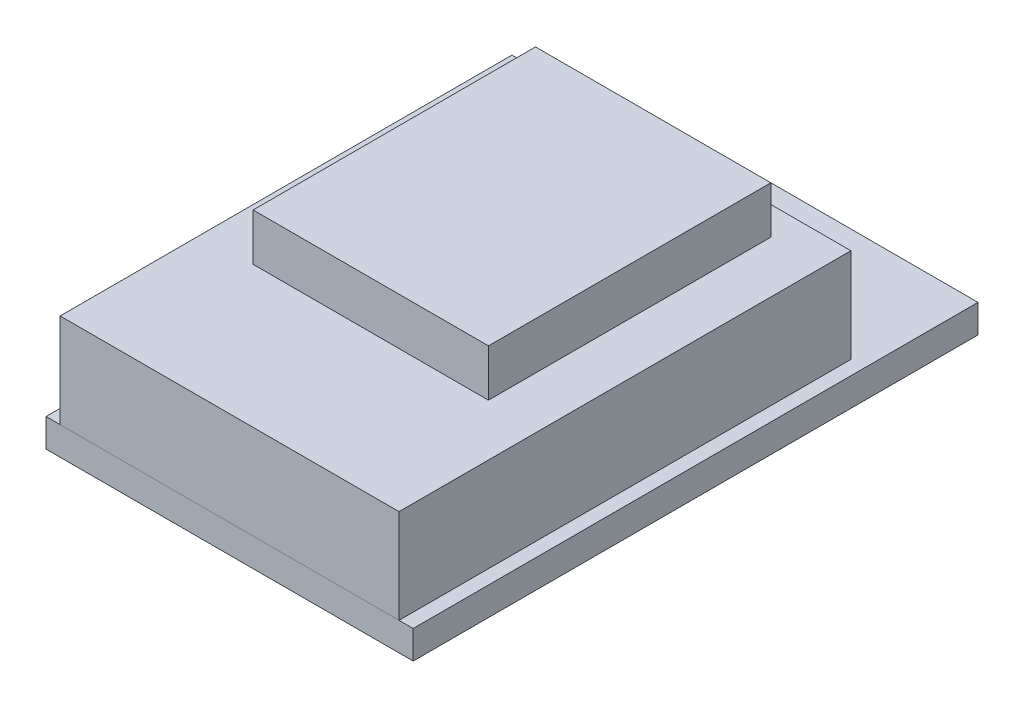
from build123d import *

# Parameters (mm, degrees)
SKETCH_1_W        = 19.5
SKETCH_1_H        = 30
EXTRUDE_1_DEPTH   = 1.5
SKETCH_2_W        = 2.54
SKETCH_2_H        = 20.32
EXTRUDE_2_DEPTH   = 2.54
EXTRUDE_2_2_DEPTH = 2.54
SKETCH_3_W        = 18
SKETCH_3_H        = 24
EXTRUDE_3_DEPTH   = 5
SKETCH_4_W        = 12.5
SKETCH_4_H        = 15
EXTRUDE_4_DEPTH   = 2.5


with BuildPart() as part:
    # Эскиз1 → Бобышка-Вытянуть1 (new body)
    with BuildSketch(Plane(origin=(0, 0, 0), x_dir=(1, 0, 0), z_dir=(0, 1, 0))):
        Rectangle(SKETCH_1_W, SKETCH_1_H)
    extrude(amount=EXTRUDE_1_DEPTH)


with BuildPart() as body_2:
    # Эскиз2 → Бобышка-Вытянуть2 (new body)
    with BuildSketch(Plane.XZ):
        with Locations((-3.81, 1.03)):
            Rectangle(SKETCH_2_W, SKETCH_2_H)
    extrude(amount=EXTRUDE_2_DEPTH)


with BuildPart() as body_3:
    # Эскиз2 → Extrude 2 2 (new body)
    with BuildSketch(Plane.XZ):
        with Locations((3.81, 1.03)):
            Rectangle(SKETCH_2_W, SKETCH_2_H)
    extrude(amount=EXTRUDE_2_2_DEPTH)


with BuildPart() as body_4:
    # Эскиз3 → Бобышка-Вытянуть3 (new body)
    with BuildSketch(Plane(origin=(0, 1.5, 0), x_dir=(1, 0, 0), z_dir=(0, 1, 0))):
        with Locations((0, -3)):
            Rectangle(SKETCH_3_W, SKETCH_3_H)
    extrude(amount=EXTRUDE_3_DEPTH)


with BuildPart() as body_5:
    # Эскиз4 → Бобышка-Вытянуть4 (new body)
    with BuildSketch(Plane(origin=(0, 6.5, 0), x_dir=(1, 0, 0), z_dir=(0, 1, 0))):
        Rectangle(SKETCH_4_W, SKETCH_4_H)
    extrude(amount=EXTRUDE_4_DEPTH)


solid = Compound([part.part, body_2.part, body_3.part, body_4.part, body_5.part])
